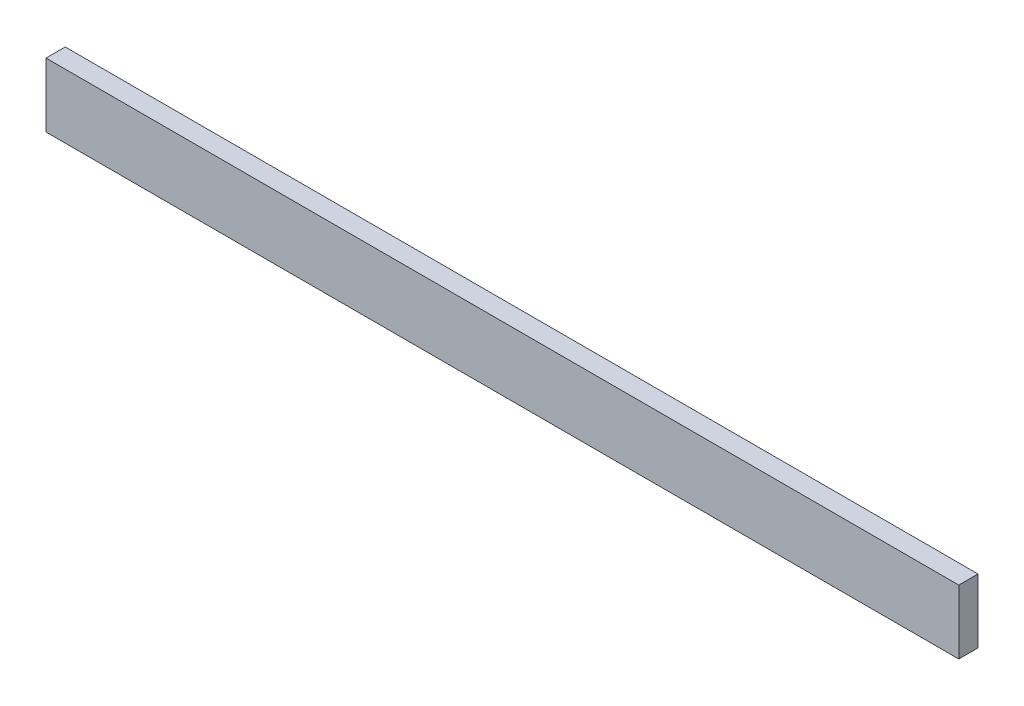
from build123d import *

# Parameters (mm, degrees)
MODEL_W             = 285
MODEL_H             = 20
BOSS_EXTRUDE1_DEPTH = 6


with BuildPart() as part:
    # Model → Boss-Extrude1 (new body)
    with BuildSketch(Plane.XY):
        with Locations((171.218655551, 21.618157131)):
            Rectangle(MODEL_W, MODEL_H)
    extrude(amount=BOSS_EXTRUDE1_DEPTH)


solid = part.part
